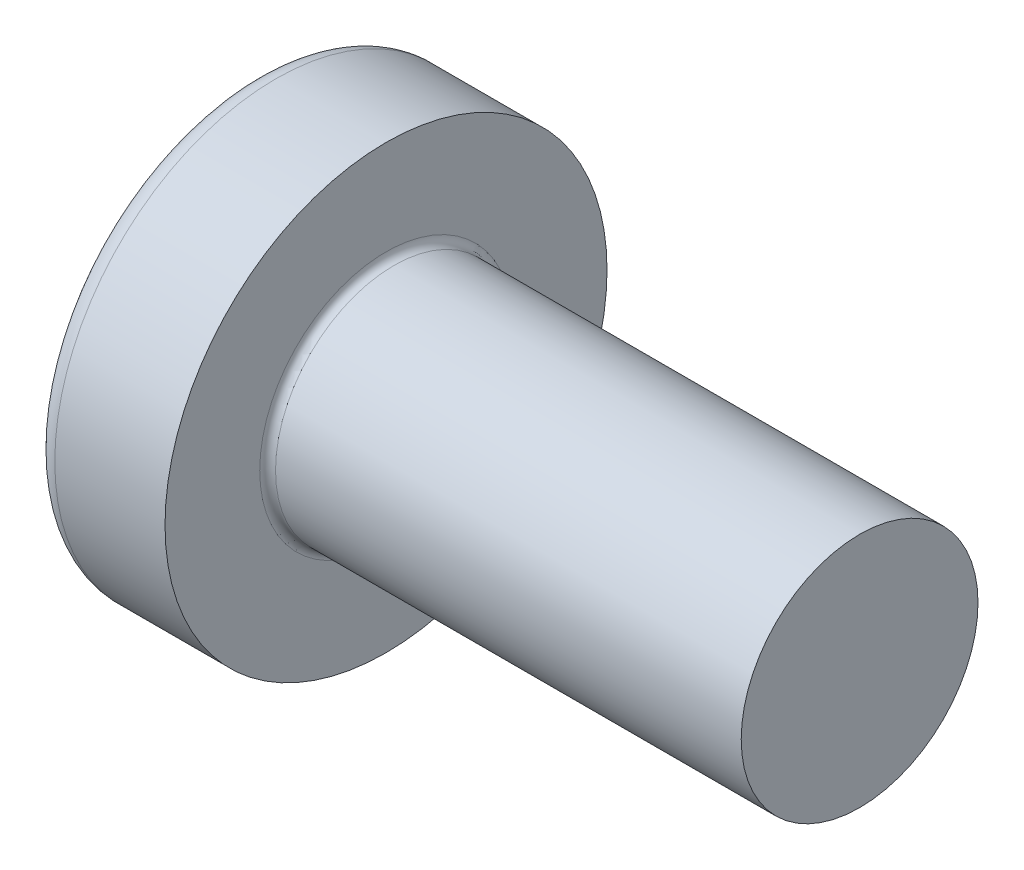
from build123d import *

# Parameters (mm, degrees)
FILLET1_R    = 0.1
SKETCH3_W    = 0.74
SKETCH3_H    = 2.8
SKETCH4_W    = 0.74
SKETCH4_H    = 1.054964432
RECPAT_COUNT = 2
RECPAT_ANGLE = 90


with BuildPart() as part:
    # BodySke → Base-Revolve (revolve)
    with BuildSketch(Plane.XY):
        with BuildLine():
            Line((2.4, 1.5), (2.4, 2.8))
            Line((2.4, 2.8), (1.003501533, 2.8))
            ThreePointArc((1.003501533, 2.8), (0.873295971, 2.76653015), (0.775371599, 2.674418605))
            ThreePointArc((0.775371599, 2.674418605), (0.197753546, 1.392274756), (0, 0))
            Line((0, 0), (8.4, 0))
            Line((8.4, 0), (8.4, 1.5))
            Line((8.4, 1.5), (2.4, 1.5))
        make_face()
    revolve(axis=Axis((-25.4, 0, 0), (1, 0, 0)))

    # Fillet1
    fillet1_edges = [part.edges().sort_by_distance(p)[0] for p in [
        (2.4, -1.5, 0),
    ]]
    fillet(fillet1_edges, radius=FILLET1_R)

    # Sketch3 → Recess section 0
    with BuildSketch(Plane(origin=(0, 0, 0), x_dir=(0, 0, -1), z_dir=(1, 0, 0))):
        Rectangle(SKETCH3_W, SKETCH3_H)
    # Sketch4 → Recess section 1
    with BuildSketch(Plane(origin=(1.75, 0, 0), x_dir=(0, 0, -1), z_dir=(1, 0, 0))):
        Rectangle(SKETCH4_W, SKETCH4_H)
    recess = loft(mode=Mode.SUBTRACT)

    # RecPat: Recess ×2 about axis
    recpat_axis = Axis((0, 0, 0), (1, 0, 0))
    for i in range(1, RECPAT_COUNT):
        add(recess.rotate(recpat_axis, i * RECPAT_ANGLE / (RECPAT_COUNT - 1)), mode=Mode.SUBTRACT)

    # RecCorSke → RecessCore (revolve, cut)
    with BuildSketch(Plane.XY):
        Polygon((0, 0), (0, 0.678371921), (1.75, 0.556), (1.930655351, 0), align=None)
    revolve(axis=Axis((-3.175, 0, 0), (1, 0, 0)), mode=Mode.SUBTRACT)


solid = part.part
